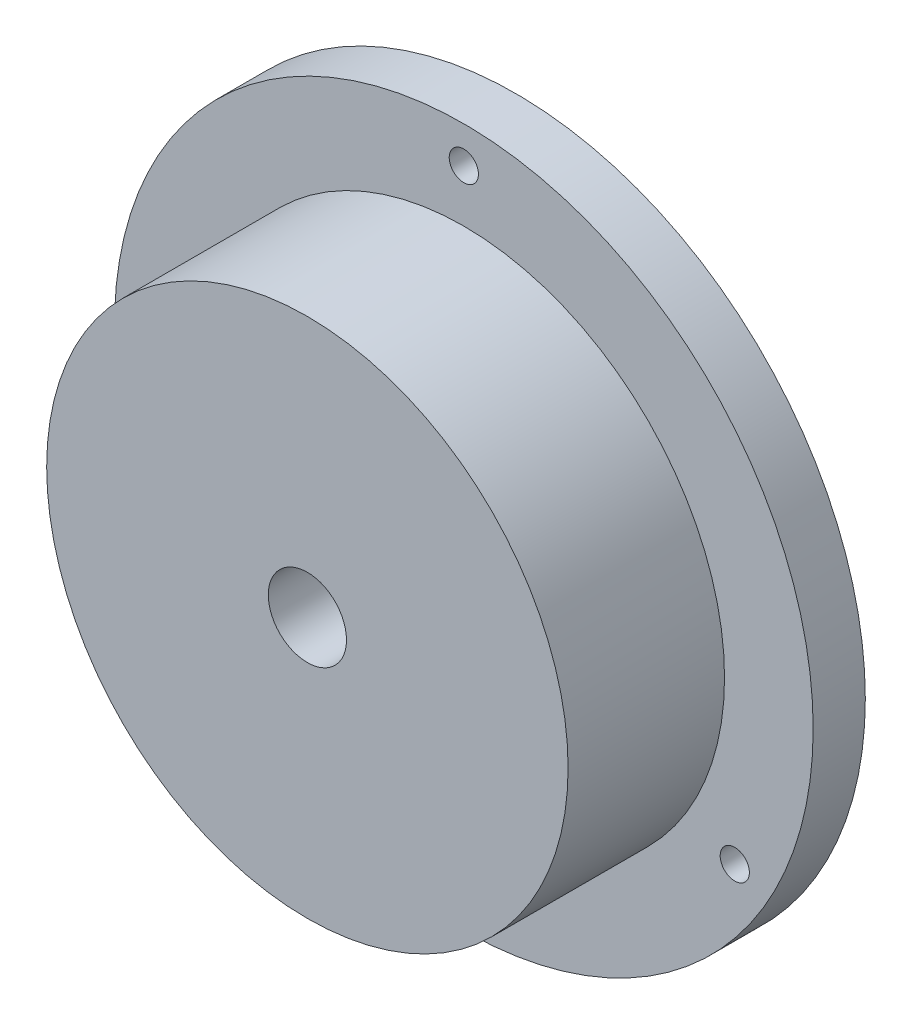
from build123d import *

# Parameters (mm, degrees)
SKETCH1_R                      = 21.2725
BOSS_EXTRUDE1_DEPTH            = 3.175
SKETCH2_R                      = 15.875
BOSS_EXTRUDE2_DEPTH            = 9.525
F_3_16_0_1875_DIAMETER_HOLE1_D = 4.7625
F_2_56_TAPPED_HOLE3_D          = 1.778
CIRPATTERN1_COUNT              = 3
F_8_32_TAPPED_HOLE1_D          = 3.4544
F_8_32_TAPPED_HOLE1_DEPTH      = 21.2715
F_8_32_TAPPED_HOLE1_TIP        = 1.037806461


with BuildPart() as part:
    # Sketch1 → Boss-Extrude1 (new body)
    with BuildSketch(Plane.XY):
        Circle(SKETCH1_R)
    extrude(amount=BOSS_EXTRUDE1_DEPTH)

    # Sketch2 → Boss-Extrude2 (add)
    with BuildSketch(Plane.XY.offset(3.175)):
        Circle(SKETCH2_R)
    extrude(amount=BOSS_EXTRUDE2_DEPTH)

    # 3/16 (0.1875) Diameter Hole1 (through all)
    with Locations(Plane.XY.offset(12.7)):
        with Locations((0, 0)):
            Hole(F_3_16_0_1875_DIAMETER_HOLE1_D / 2)

    # #2-56 Tapped Hole3 (through all)
    with Locations(Plane.XY.offset(3.175)):
        with Locations((0, 19.05)):
            f_2_56_tapped_hole3 = Hole(F_2_56_TAPPED_HOLE3_D / 2)

    # CirPattern1: #2-56 Tapped Hole3 ×3 about axis
    cirpattern1_axis = Axis((0, 0, 0), (0, 0, 1))
    for i in range(1, CIRPATTERN1_COUNT):
        add(f_2_56_tapped_hole3.rotate(cirpattern1_axis, i * 360 / CIRPATTERN1_COUNT), mode=Mode.SUBTRACT)

    # #8-32 Tapped Hole1
    with Locations(Plane.XZ.offset(21.2725)):
        with Locations((0, 7.9248)):
            Hole(F_8_32_TAPPED_HOLE1_D / 2, depth=F_8_32_TAPPED_HOLE1_DEPTH)
            with Locations((0, 0, -(F_8_32_TAPPED_HOLE1_DEPTH + F_8_32_TAPPED_HOLE1_TIP / 2))):  # 118° drill point
                Cone(0, F_8_32_TAPPED_HOLE1_D / 2, F_8_32_TAPPED_HOLE1_TIP, mode=Mode.SUBTRACT)


solid = part.part
